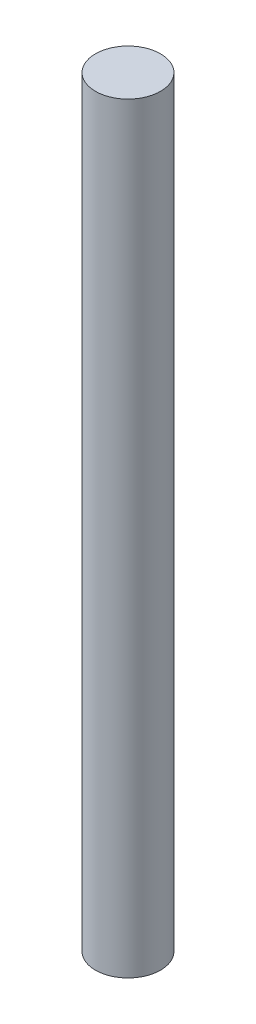
from build123d import *

# Parameters (mm, degrees)
SKETCH1_R           = 3.175
BOSS_EXTRUDE1_DEPTH = 74.295


with BuildPart() as part:
    # Sketch1 → Boss-Extrude1 (new body)
    with BuildSketch(Plane(origin=(0, 0, 0), x_dir=(1, 0, 0), z_dir=(0, 1, 0))):
        Circle(SKETCH1_R)
    extrude(amount=BOSS_EXTRUDE1_DEPTH)


solid = part.part
